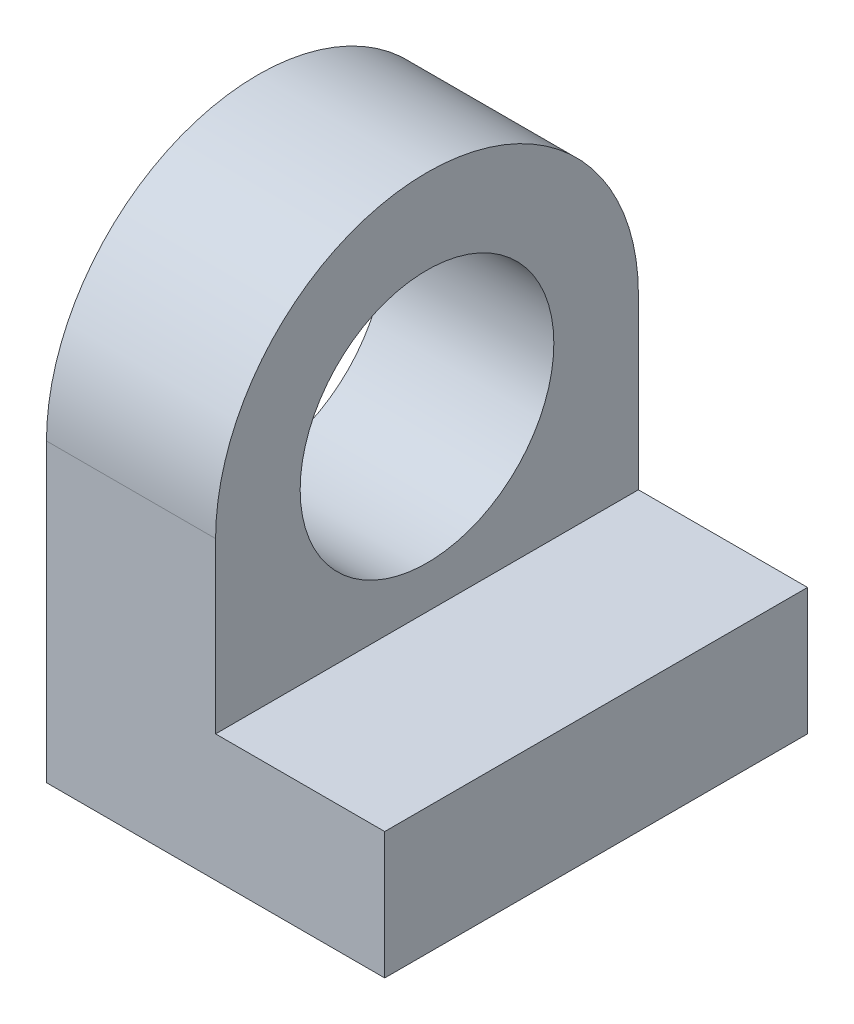
from build123d import *

# Parameters (mm, degrees)
CROQUIS1_R              = 7.5
SALIENTE_EXTRUIR1_DEPTH = 20
CORTAR_EXTRUIR1_REACH   = 27
CROQUIS2_W              = 10
CROQUIS2_H              = 22.5


with BuildPart() as part:
    # Croquis1 → Saliente-Extruir1 (new body)
    with BuildSketch(Plane(origin=(0, 0, 0), x_dir=(0, 0, -1), z_dir=(1, 0, 0))):
        with BuildLine():
            Line((0, 0), (25, 0))
            Line((25, 0), (25, 17.5))
            ThreePointArc((25, 17.5), (12.5, 30), (0, 17.5))
            Line((0, 17.5), (0, 0))
        make_face()
        with Locations((12.5, 17.5)):
            Circle(CROQUIS1_R, mode=Mode.SUBTRACT)
    extrude(amount=-SALIENTE_EXTRUIR1_DEPTH)

    # Croquis2 → Cortar-Extruir1 (cut, up to next)
    with BuildSketch(Plane.XY, mode=Mode.PRIVATE) as cortar_extruir1_sk1:
        with Locations((-5, 18.75)):
            Rectangle(CROQUIS2_W, CROQUIS2_H)
    cortar_extruir1_tool1 = extrude(cortar_extruir1_sk1.sketch, amount=-CORTAR_EXTRUIR1_REACH, mode=Mode.PRIVATE) & part.part
    add(cortar_extruir1_tool1.solids().sort_by_distance((-5, 18.75, 0))[0], mode=Mode.SUBTRACT)


solid = part.part
